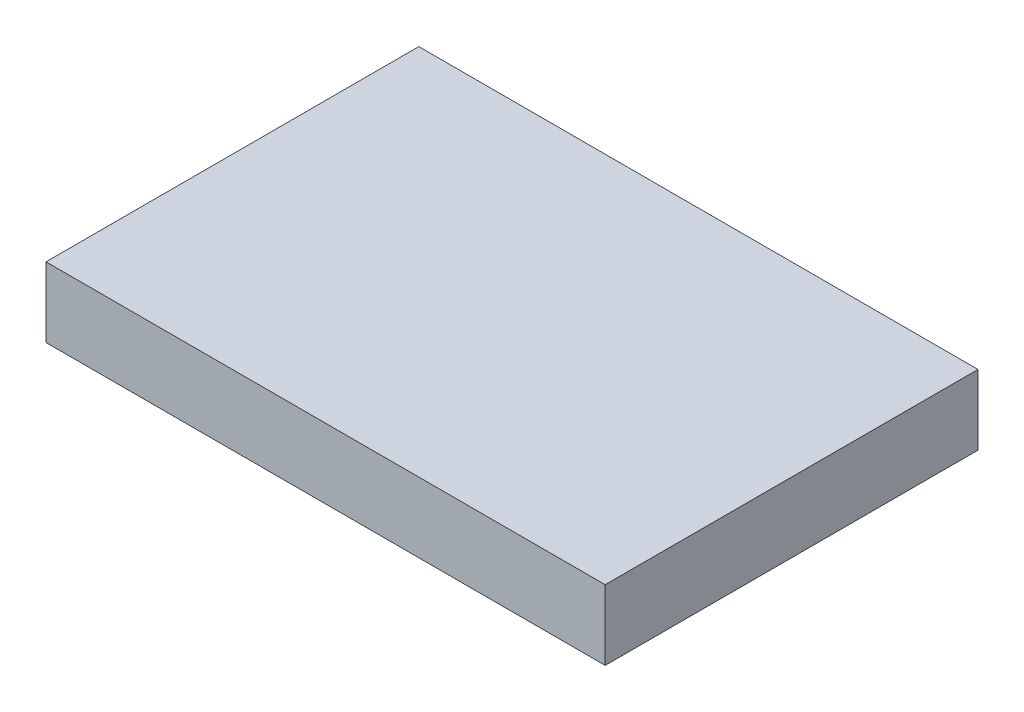
from build123d import *

# Parameters (mm, degrees)
ESQUISSE2_W        = 24
ESQUISSE2_H        = 16
BOSS_EXTRU_1_DEPTH = 3


with BuildPart() as part:
    # Esquisse2 → Boss.-Extru.1 (new body)
    with BuildSketch(Plane(origin=(0, 0, 0), x_dir=(1, 0, 0), z_dir=(0, 1, 0))):
        with Locations((12, 8)):
            Rectangle(ESQUISSE2_W, ESQUISSE2_H)
    extrude(amount=BOSS_EXTRU_1_DEPTH)


solid = part.part
